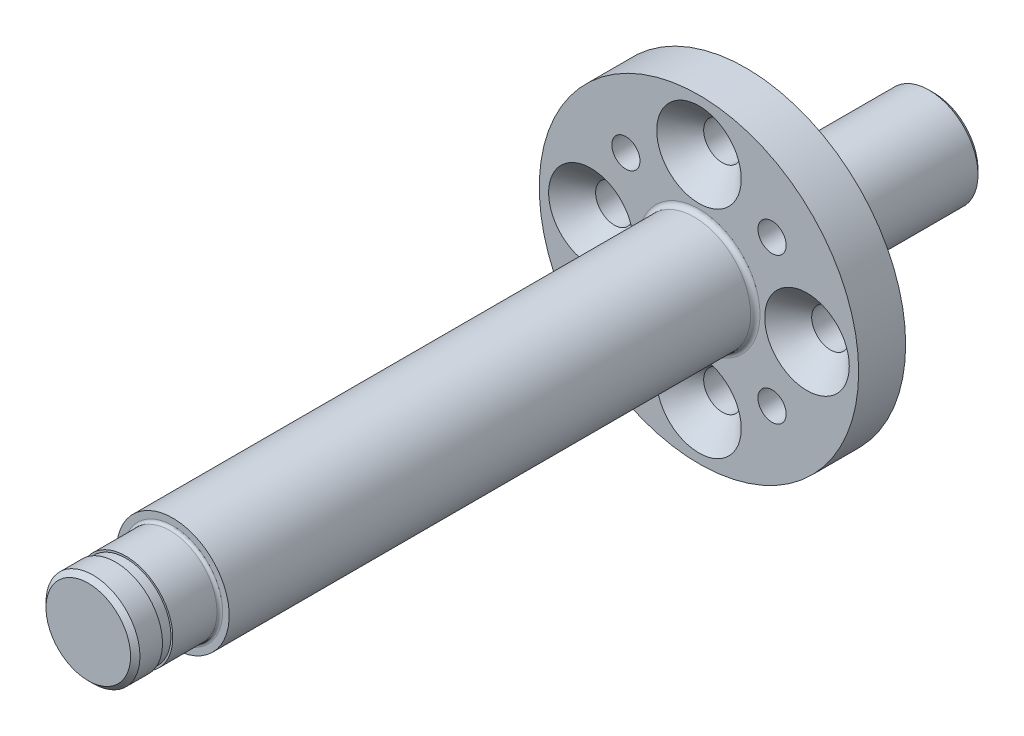
from build123d import *

# Parameters (mm, degrees)
SKETCH1_R                                            = 17
BOSS_EXTRUDE1_DEPTH                                  = 5
SKETCH3_R                                            = 5.2
BOSS_EXTRUDE3_DEPTH                                  = 20
CSK_FOR_M4_HEX_SOCKET_COUNTERSUNK_CAP_SC_D           = 4
CSK_FOR_M4_HEX_SOCKET_COUNTERSUNK_CAP_SC_CSINK_D     = 9
CSK_FOR_M4_HEX_SOCKET_COUNTERSUNK_CAP_SC_CSINK_ANGLE = 90
M4_TAPPED_HOLE1_D                                    = 3
CHAMFER1_SIZE                                        = 0.5
FILLET1_R                                            = 0.3
FILLET2_R                                            = 0.5


with BuildPart() as part:
    # Sketch1 → Boss-Extrude1 (new body)
    with BuildSketch(Plane.XY):
        Circle(SKETCH1_R)
    extrude(amount=BOSS_EXTRUDE1_DEPTH)

    # Sketch3 → Boss-Extrude3 (add)
    with BuildSketch(Plane(origin=(0, 0, 0), x_dir=(-1, 0, 0), z_dir=(0, 0, -1))):
        Circle(SKETCH3_R)
    extrude(amount=BOSS_EXTRUDE3_DEPTH)

    # CSK for M4 Hex Socket Countersunk Cap Screw1 (through all)
    with Locations(Plane.XY.offset(5)):
        with Locations((0, 11.5), (11.5, 0), (0, -11.5), (-11.5, 0)):
            CounterSinkHole(CSK_FOR_M4_HEX_SOCKET_COUNTERSUNK_CAP_SC_D / 2, CSK_FOR_M4_HEX_SOCKET_COUNTERSUNK_CAP_SC_CSINK_D / 2, counter_sink_angle=CSK_FOR_M4_HEX_SOCKET_COUNTERSUNK_CAP_SC_CSINK_ANGLE)

    # M4 Tapped Hole1 (through all)
    with Locations(Plane.XY.offset(5)):
        with Locations((7.778174593, 7.778174593), (-7.778174593, -7.778174593), (-7.778174593, 7.778174593), (7.778174593, -7.778174593)):
            Hole(M4_TAPPED_HOLE1_D / 2)

    # Sketch10 → Revolve1 (revolve)
    with BuildSketch(Plane(origin=(0, 0, 0), x_dir=(0, 0, -1), z_dir=(1, 0, 0))):
        Polygon((-5, 0), (-5, 6), (-61, 6), (-61, 5), (-66, 5), (-66, 4.8), (-67.1, 4.8), (-67.1, 5), (-70, 5), (-70, 0), align=None)
    revolve(axis=Axis((0, 0, -20), (0, 0, 1)))

    # Chamfer1
    chamfer1_edges = [part.edges().sort_by_distance(p)[0] for p in [
        (5.2, 0, -20),
        (0, -5, 70),
    ]]
    chamfer(chamfer1_edges, length=CHAMFER1_SIZE)

    # Fillet1
    fillet1_edges = [part.edges().sort_by_distance(p)[0] for p in [
        (0, -5, 61),
    ]]
    fillet(fillet1_edges, radius=FILLET1_R)

    # Fillet2
    fillet2_edges = [part.edges().sort_by_distance(p)[0] for p in [
        (5.2, 0, 0),
        (0, -6, 5),
    ]]
    fillet(fillet2_edges, radius=FILLET2_R)


solid = part.part
